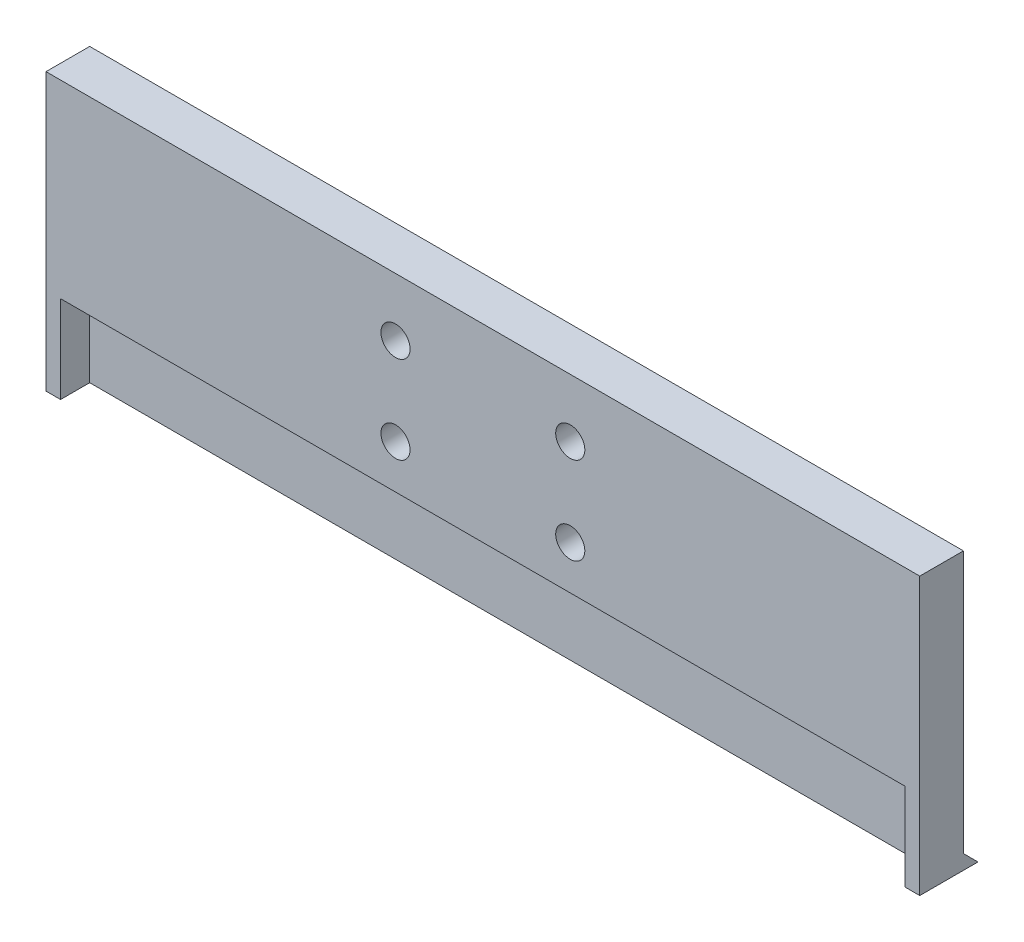
from build123d import *

# Parameters (mm, degrees)
ESQUISSE1_W             = 300
ESQUISSE1_H             = 95
BOSS_EXTRU_1_DEPTH      = 5
BOSS_EXTRU_2_DEPTH      = 300
BOSS_EXTRU_3_DEPTH      = 10
ESQUISSE6_R             = 5
ENL_V_MAT_EXTRU_2_DEPTH = 16
ESQUISSE7_W             = 290
ESQUISSE7_H             = 23.020862504
ENL_V_MAT_EXTRU_3_DEPTH = 30


with BuildPart() as part:
    # Esquisse1 → Boss.-Extru.1 (new body)
    with BuildSketch(Plane.XY):
        with Locations((150, 47.5)):
            Rectangle(ESQUISSE1_W, ESQUISSE1_H)
    extrude(amount=BOSS_EXTRU_1_DEPTH)

    # Esquisse3 → Boss.-Extru.2 (add)
    with BuildSketch(Plane.ZY):
        Polygon((-5, 0), (0, 0), (0, 5), align=None)
    extrude(amount=-BOSS_EXTRU_2_DEPTH)

    # Esquisse5 → Boss.-Extru.3 (add)
    with BuildSketch(Plane.XY.offset(5)):
        Polygon((195, 95), (105, 95), (0, 95), (0, 30), (0, 0), (300, 0), (300, 30), (300, 95), align=None)
    extrude(amount=BOSS_EXTRU_3_DEPTH)

    # Esquisse6 → Enlèv. mat.-Extru.2 (cut, through all)
    with BuildSketch(Plane(origin=(0, 0, 0), x_dir=(-1, 0, 0), z_dir=(0, 0, -1))):
        with Locations((-180, 75)):
            Circle(ESQUISSE6_R)
        with Locations((-180, 45)):
            Circle(ESQUISSE6_R)
        with Locations((-120, 45)):
            Circle(ESQUISSE6_R)
        with Locations((-120, 75)):
            Circle(ESQUISSE6_R)
    extrude(amount=-ENL_V_MAT_EXTRU_2_DEPTH, mode=Mode.SUBTRACT)

    # Esquisse7 → Enlèv. mat.-Extru.3 (cut)
    with BuildSketch(Plane.XZ):
        with Locations((150, 16.510431252)):
            Rectangle(ESQUISSE7_W, ESQUISSE7_H)
    extrude(amount=-ENL_V_MAT_EXTRU_3_DEPTH, mode=Mode.SUBTRACT)


solid = part.part
